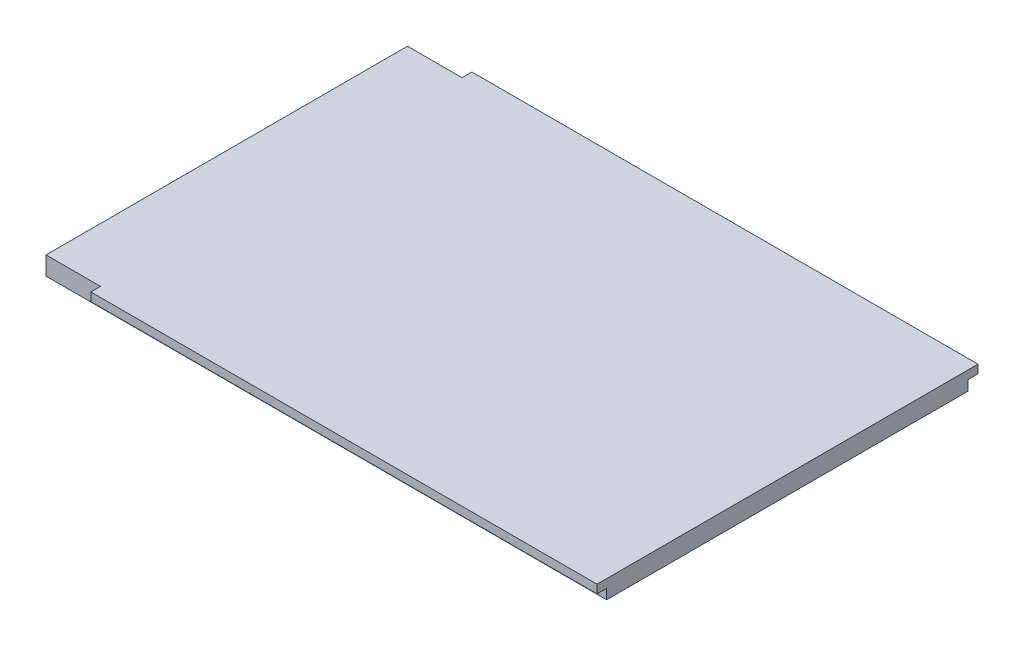
from build123d import *

# Parameters (mm, degrees)
ESQUISSE1_W        = 465.25
ESQUISSE1_H        = 15.25
BOSS_EXTRU_1_DEPTH = 300
ESQUISSE2_W        = 316.17735242
ESQUISSE2_H        = 7
BOSS_EXTRU_2_DEPTH = 420


with BuildPart() as part:
    # Esquisse1 → Boss.-Extru.1 (new body)
    with BuildSketch(Plane.XY):
        with Locations((232.625, -12.561135371)):
            Rectangle(ESQUISSE1_W, ESQUISSE1_H)
    extrude(amount=BOSS_EXTRU_1_DEPTH)

    # Esquisse2 → Boss.-Extru.2 (add)
    with BuildSketch(Plane(origin=(465.25, 0, 0), x_dir=(0, 0, -1), z_dir=(1, 0, 0))):
        with Locations((-149.91132379, -8.436135371)):
            Rectangle(ESQUISSE2_W, ESQUISSE2_H)
    extrude(amount=-BOSS_EXTRU_2_DEPTH)


solid = part.part
